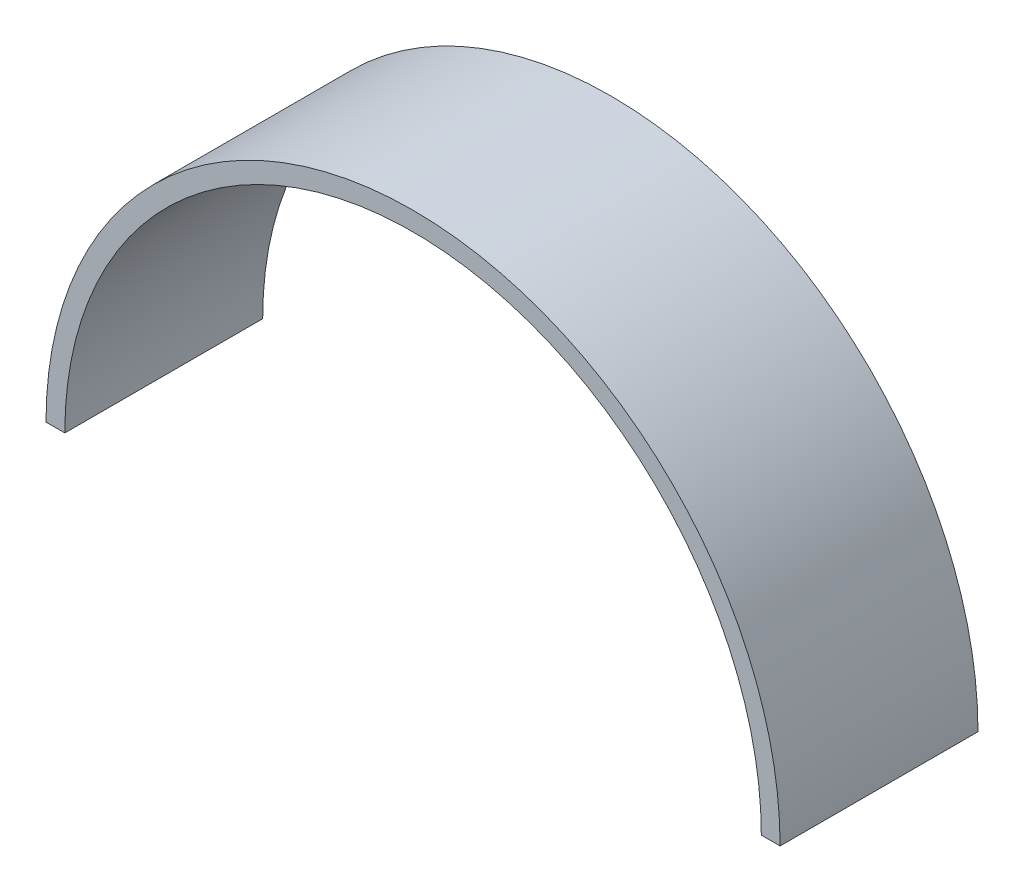
from build123d import *

# Parameters (mm, degrees)
BOSS_EXTRUDE1_DEPTH = 25.4


with BuildPart() as part:
    # Sketch1 → Boss-Extrude1 (new body)
    with BuildSketch(Plane.XY):
        with BuildLine():
            Line((-47.117, 0), (-44.704, 0))
            ThreePointArc((-44.704, 0), (0, 44.704), (44.704, 0))
            Line((44.704, 0), (47.117, 0))
            ThreePointArc((47.117, 0), (0, 47.117), (-47.117, 0))
        make_face()
    extrude(amount=BOSS_EXTRUDE1_DEPTH)


solid = part.part
